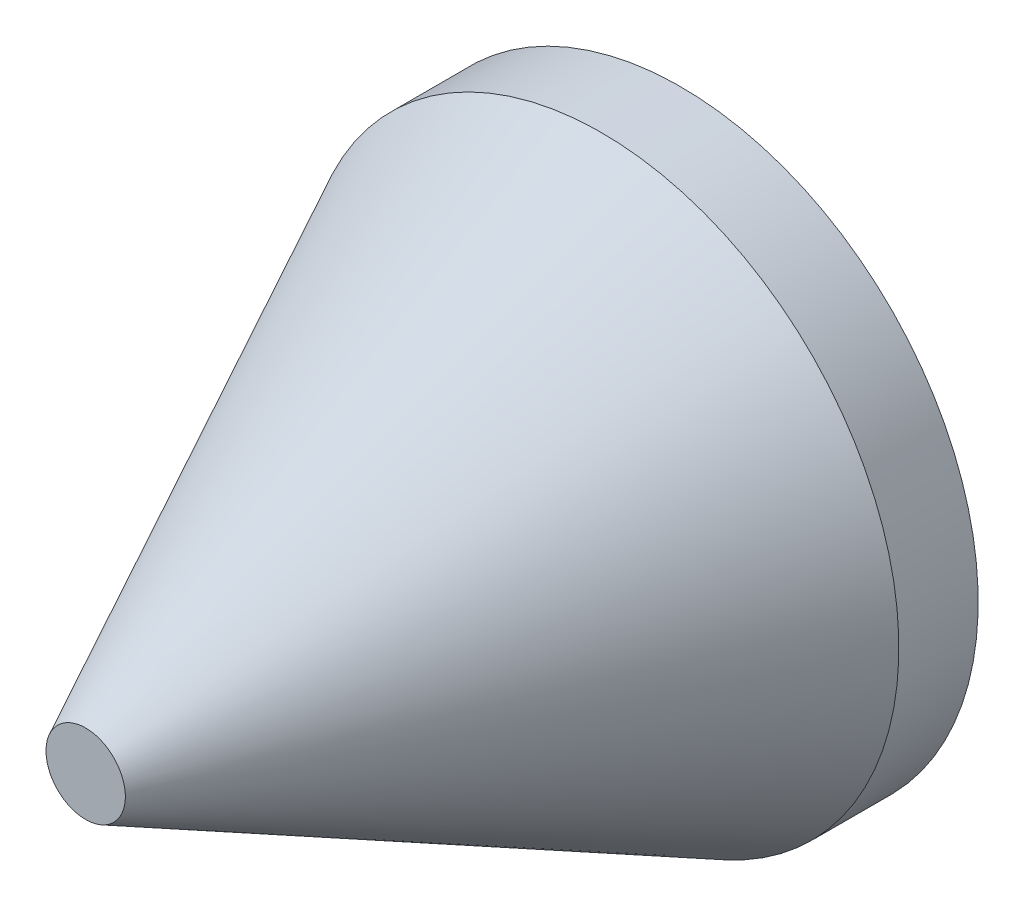
from build123d import *


with BuildPart() as part:
    # Sketch1 → Revolve1 (revolve)
    with BuildSketch(Plane(origin=(0, 0, 0), x_dir=(1, 0, 0), z_dir=(0, 1, 0))):
        Polygon((75, 0), (0, 0), (0, -150), (10, -150), (75, -20), align=None)
    revolve(axis=Axis((0, 0, -14.543889845), (0, 0, 1)))


solid = part.part
